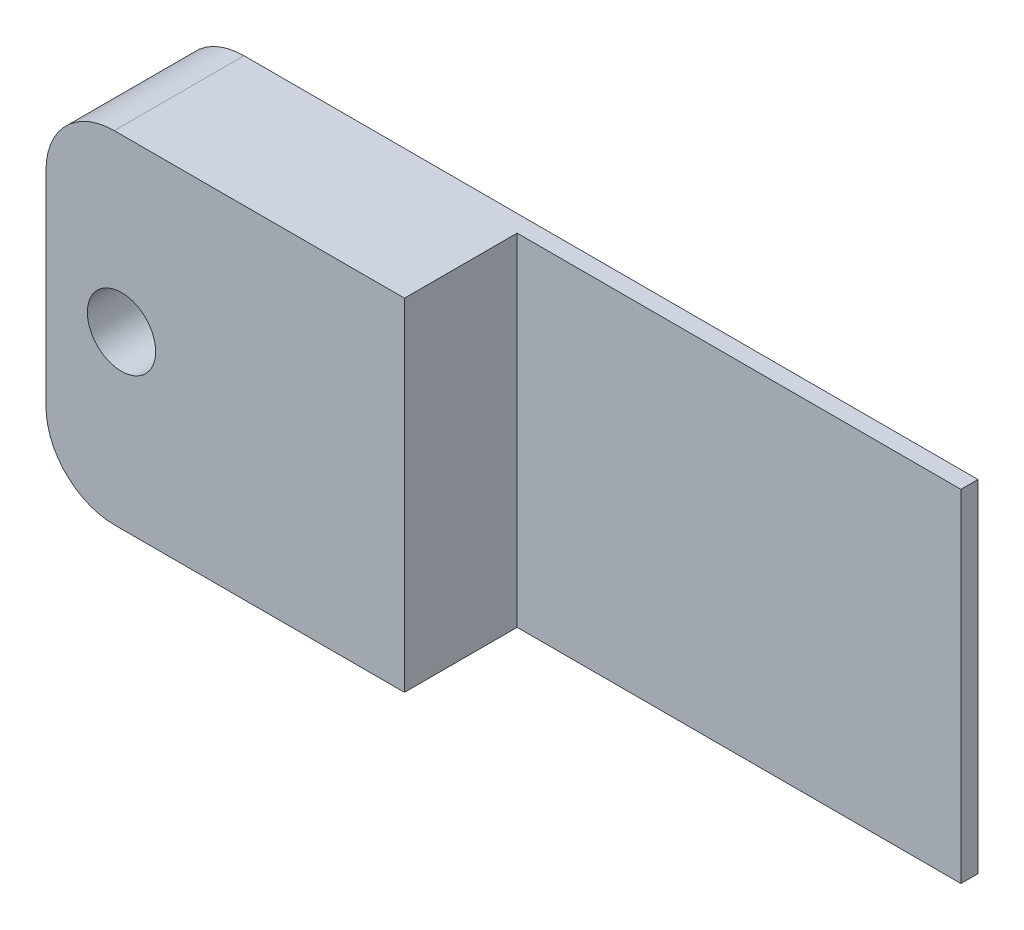
from build123d import *

# Parameters (mm, degrees)
SKETCH_1_R          = 1
EXTRUDE_1_DEPTH     = 3.8
SKETCH_2_W          = 13
SKETCH_2_H          = 10
CUT_EXTRUDE_1_DEPTH = 3.3


with BuildPart() as part:
    # Эскиз1 → Бобышка-Вытянуть1 (new body)
    with BuildSketch(Plane.XY):
        with BuildLine():
            Line((-9.75, 5), (11.75, 5))
            Line((11.75, 5), (11.75, -5))
            Line((11.75, -5), (-9.75, -5))
            ThreePointArc((-9.75, -5), (-11.164213562, -4.414213562), (-11.75, -3))
            Line((-11.75, -3), (-11.75, 3))
            ThreePointArc((-11.75, 3), (-11.164213562, 4.414213562), (-9.75, 5))
        make_face()
        with Locations((-9.538461538, 0)):
            Circle(SKETCH_1_R, mode=Mode.SUBTRACT)
    extrude(amount=EXTRUDE_1_DEPTH)

    # Эскиз2 → Вырез-Вытянуть1 (cut)
    with BuildSketch(Plane.XY.offset(3.8)):
        with Locations((5.25, 0)):
            Rectangle(SKETCH_2_W, SKETCH_2_H)
    extrude(amount=-CUT_EXTRUDE_1_DEPTH, mode=Mode.SUBTRACT)


solid = part.part
